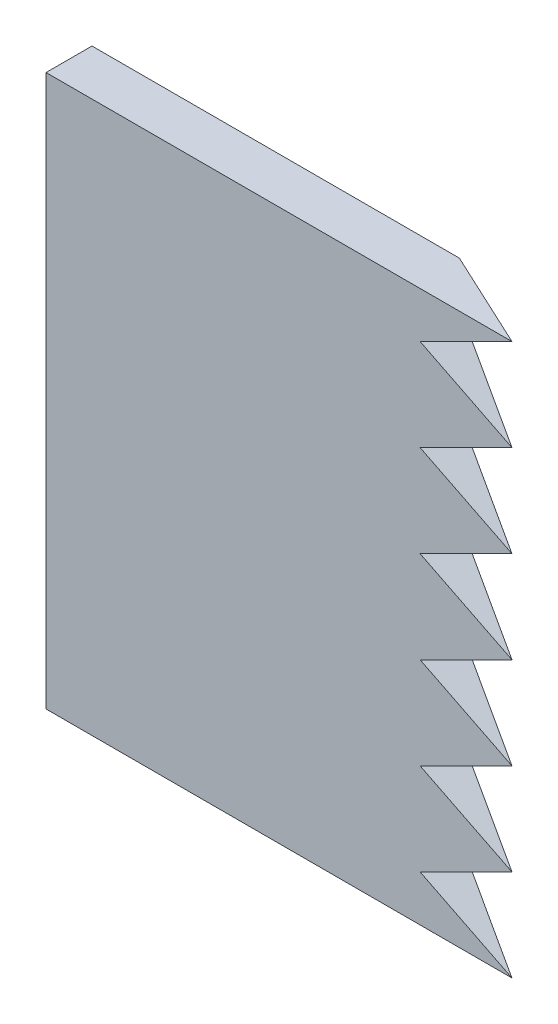
from build123d import *

# Parameters (mm, degrees)
BOSS_EXTRUDE1_DEPTH = 76.2
CUT_EXTRUDE1_DEPTH  = 7.35


with BuildPart() as part:
    # Sketch1 → Boss-Extrude1 (new body)
    with BuildSketch(Plane(origin=(0, 0, 0), x_dir=(1, 0, 0), z_dir=(0, 1, 0))):
        Polygon((0, -146.05), (64.407023089, -146.05), (50.789404144, -139.7), (0, -139.7), align=None)
    extrude(amount=BOSS_EXTRUDE1_DEPTH)

    # Sketch2 → Cut-Extrude1 (cut, through all)
    with BuildSketch(Plane.XY.offset(146.05)):
        Polygon((64.407023089, 0), (64.407023089, 12.7), (51.707023089, 6.35), align=None)
        Polygon((64.407023089, 12.7), (64.407023089, 25.4), (51.707023089, 19.05), align=None)
        Polygon((64.407023089, 25.4), (64.407023089, 38.1), (51.707023089, 31.75), align=None)
        Polygon((64.407023089, 38.1), (64.407023089, 50.8), (51.707023089, 44.45), align=None)
        Polygon((64.407023089, 50.8), (64.407023089, 63.5), (51.707023089, 57.15), align=None)
        Polygon((64.407023089, 63.5), (64.407023089, 76.2), (51.707023089, 69.85), align=None)
    extrude(amount=-CUT_EXTRUDE1_DEPTH, mode=Mode.SUBTRACT)


solid = part.part
